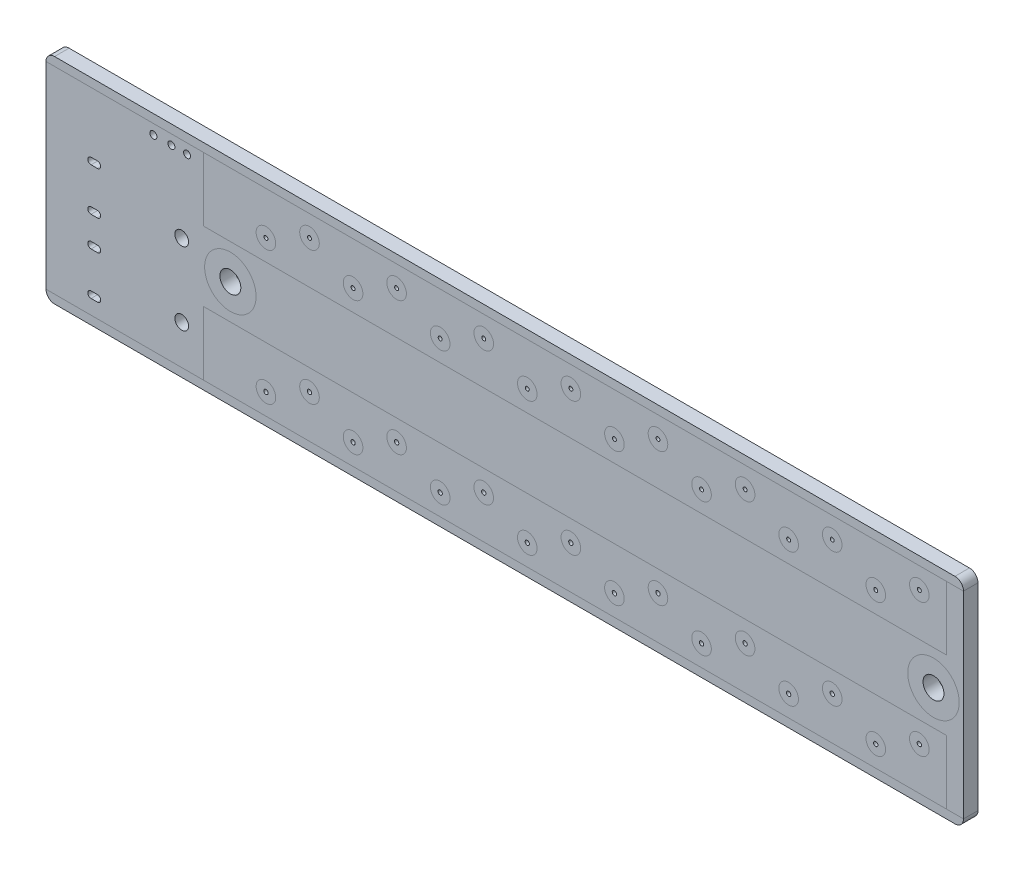
from build123d import *

# Parameters (mm, degrees)
SKETCH1_W                 = 107
SKETCH1_H                 = 25
SKETCH1_W_2               = 86.65
SKETCH1_H_2               = 7.4399
BOSS_EXTRUDE1_DEPTH       = 1.692
FILLET1_R                 = 1
F_2_CLEARANCE_HOLE1_D     = 2.4384
F_2_CLEARANCE_HOLE1_DEPTH = 8.66
F_2_CLEARANCE_HOLE1_TIP   = 0.732569267
SKETCH10_R                = 0.8
SKETCH10_R_2              = 0.4064
CUT_EXTRUDE1_DEPTH        = 10
SKETCH11_R                = 0.254
SKETCH11_R_2              = 0.23
CUT_EXTRUDE2_DEPTH        = 2.692


with BuildPart() as part:
    # Sketch1 → Boss-Extrude1 (new body)
    with BuildSketch(Plane.XY):
        Rectangle(SKETCH1_W, SKETCH1_H)
        with Locations((8.175, 7.78005)):
            Rectangle(SKETCH1_W_2, SKETCH1_H_2, mode=Mode.SUBTRACT)
        with Locations((8.175, -7.78005)):
            Rectangle(SKETCH1_W_2, SKETCH1_H_2, mode=Mode.SUBTRACT)
        with Locations((8.175, -7.78005)):
            Rectangle(SKETCH1_W_2, SKETCH1_H_2)
        with Locations((8.175, 7.78005)):
            Rectangle(SKETCH1_W_2, SKETCH1_H_2)
    extrude(amount=BOSS_EXTRUDE1_DEPTH)

    # Fillet1
    fillet1_edges = [part.edges().sort_by_distance(p)[0] for p in [
        (53.5, -12.5, 0.846),
        (-53.5, -12.5, 0.846),
        (-53.5, 12.5, 0.846),
        (53.5, 12.5, 0.846),
    ]]
    fillet(fillet1_edges, radius=FILLET1_R)

    # 2 Clearance Hole1
    with Locations(Plane(origin=(0, 0, 0), x_dir=(-1, 0, 0), z_dir=(0, 0, -1))):
        with Locations((-50, 0), (32, 0)):
            Hole(F_2_CLEARANCE_HOLE1_D / 2, depth=F_2_CLEARANCE_HOLE1_DEPTH)
            with Locations((0, 0, -(F_2_CLEARANCE_HOLE1_DEPTH + F_2_CLEARANCE_HOLE1_TIP / 2))):  # 118° drill point
                Cone(0, F_2_CLEARANCE_HOLE1_D / 2, F_2_CLEARANCE_HOLE1_TIP, mode=Mode.SUBTRACT)

    # Sketch10 → Cut-Extrude1 (cut)
    with BuildSketch(Plane(origin=(0, 0, 0), x_dir=(-1, 0, 0), z_dir=(0, 0, -1))):
        with Locations((37.675, -6.925)):
            Circle(SKETCH10_R)
        with Locations((37.675, 1.575)):
            Circle(SKETCH10_R)
        with Locations((37.05, 10.35)):
            Circle(SKETCH10_R_2)
        with Locations((38.875, 10.35)):
            Circle(SKETCH10_R_2)
        with Locations((40.975, 10.35)):
            Circle(SKETCH10_R_2)
        with BuildLine():
            Line((48.244, -4.806), (47.506, -4.806))
            ThreePointArc((47.506, -4.806), (47.125, -4.425), (47.506, -4.044))
            Line((47.506, -4.044), (48.244, -4.044))
            ThreePointArc((48.244, -4.044), (48.625, -4.425), (48.244, -4.806))
        make_face()
        with BuildLine():
            Line((48.244, -9.806), (47.506, -9.806))
            ThreePointArc((47.506, -9.806), (47.125, -9.425), (47.506, -9.044))
            Line((47.506, -9.044), (48.244, -9.044))
            ThreePointArc((48.244, -9.044), (48.625, -9.425), (48.244, -9.806))
        make_face()
        with BuildLine():
            Line((47.506, -0.544), (48.244, -0.544))
            ThreePointArc((48.244, -0.544), (48.625, -0.925), (48.244, -1.306))
            Line((48.244, -1.306), (47.506, -1.306))
            ThreePointArc((47.506, -1.306), (47.125, -0.925), (47.506, -0.544))
        make_face()
        with BuildLine():
            Line((47.506, 4.456), (48.244, 4.456))
            ThreePointArc((48.244, 4.456), (48.625, 4.075), (48.244, 3.694))
            Line((48.244, 3.694), (47.506, 3.694))
            ThreePointArc((47.506, 3.694), (47.125, 4.075), (47.506, 4.456))
        make_face()
    extrude(amount=-CUT_EXTRUDE1_DEPTH, mode=Mode.SUBTRACT)

    # Sketch11 → Cut-Extrude2 (cut, through all)
    with BuildSketch(Plane(origin=(0, 0, 0), x_dir=(-1, 0, 0), z_dir=(0, 0, -1))):
        with Locations((27.85, -9.05005)):
            Circle(SKETCH11_R)
        with Locations((22.77, -6.51005)):
            Circle(SKETCH11_R)
        with Locations((17.69, -9.05005)):
            Circle(SKETCH11_R)
        with Locations((12.61, -6.51005)):
            Circle(SKETCH11_R)
        with Locations((17.69, 6.51005)):
            Circle(SKETCH11_R_2)
        with Locations((12.61, 9.05005)):
            Circle(SKETCH11_R_2)
        with Locations((7.53, -9.05005)):
            Circle(SKETCH11_R)
        with Locations((2.45, -6.51005)):
            Circle(SKETCH11_R)
        with Locations((7.53, 6.51005)):
            Circle(SKETCH11_R_2)
        with Locations((2.45, 9.05005)):
            Circle(SKETCH11_R_2)
        with Locations((-2.63, -9.05005)):
            Circle(SKETCH11_R)
        with Locations((-7.71, -6.51005)):
            Circle(SKETCH11_R)
        with Locations((-2.63, 6.51005)):
            Circle(SKETCH11_R_2)
        with Locations((-7.71, 9.05005)):
            Circle(SKETCH11_R_2)
        with Locations((-12.79, -9.05005)):
            Circle(SKETCH11_R)
        with Locations((-17.87, -6.51005)):
            Circle(SKETCH11_R)
        with Locations((27.85, 6.51005)):
            Circle(SKETCH11_R_2)
        with Locations((22.77, 9.05005)):
            Circle(SKETCH11_R_2)
        with Locations((-12.79, 6.51005)):
            Circle(SKETCH11_R_2)
        with Locations((-17.87, 9.05005)):
            Circle(SKETCH11_R_2)
        with Locations((-22.95, -9.05005)):
            Circle(SKETCH11_R)
        with Locations((-28.03, -6.51005)):
            Circle(SKETCH11_R)
        with Locations((-22.95, 6.51005)):
            Circle(SKETCH11_R_2)
        with Locations((-28.03, 9.05005)):
            Circle(SKETCH11_R_2)
        with Locations((-33.11, -9.05005)):
            Circle(SKETCH11_R)
        with Locations((-38.19, -6.51005)):
            Circle(SKETCH11_R)
        with Locations((-33.11, 6.51005)):
            Circle(SKETCH11_R_2)
        with Locations((-38.19, 9.05005)):
            Circle(SKETCH11_R_2)
        with Locations((-43.27, -9.05005)):
            Circle(SKETCH11_R)
        with Locations((-48.35, -6.51005)):
            Circle(SKETCH11_R)
        with Locations((-43.27, 6.51005)):
            Circle(SKETCH11_R_2)
        with Locations((-48.35, 9.05005)):
            Circle(SKETCH11_R_2)
    extrude(amount=-CUT_EXTRUDE2_DEPTH, mode=Mode.SUBTRACT)


solid = part.part
